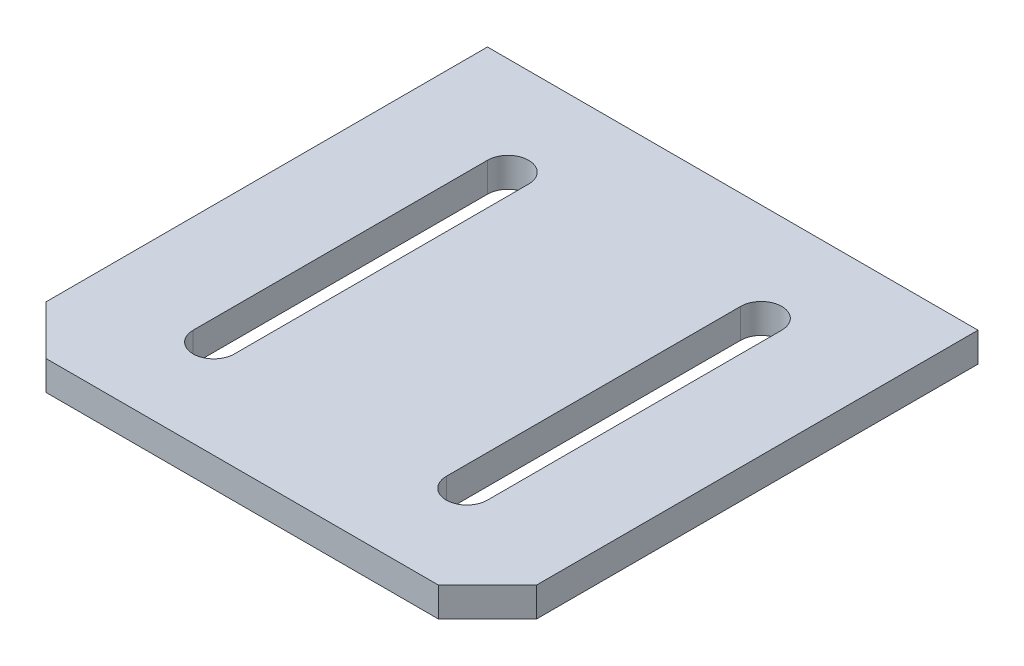
from build123d import *

# Parameters (mm, degrees)
SKETCH1_W           = 50
SKETCH1_H           = 50
BOSS_EXTRUDE1_DEPTH = 3
CHAMFER1_SIZE       = 5
CUT_EXTRUDE1_DEPTH  = 10


with BuildPart() as part:
    # Sketch1 → Boss-Extrude1 (new body)
    with BuildSketch(Plane(origin=(0, 0, 0), x_dir=(1, 0, 0), z_dir=(0, 1, 0))):
        Rectangle(SKETCH1_W, SKETCH1_H)
    extrude(amount=BOSS_EXTRUDE1_DEPTH)

    # Chamfer1
    chamfer1_edges = [part.edges().sort_by_distance(p)[0] for p in [
        (25, 1.5, 25),
        (-25, 1.5, 25),
    ]]
    chamfer(chamfer1_edges, length=CHAMFER1_SIZE)

    # Sketch2 → Cut-Extrude1 (cut)
    with BuildSketch(Plane(origin=(0, 3, 0), x_dir=(1, 0, 0), z_dir=(0, 1, 0))):
        with BuildLine():
            Line((-10.8, -15), (-10.8, 15))
            ThreePointArc((-10.8, 15), (-12.9, 12.9), (-15, 15))
            Line((-15, 15), (-15, -15))
            ThreePointArc((-15, -15), (-12.9, -12.9), (-10.8, -15))
        make_face()
        with BuildLine():
            ThreePointArc((-15, 15), (-12.9, 12.9), (-10.8, 15))
            Line((-10.8, 15), (-15, 15))
        make_face()
        with BuildLine():
            Line((-15, 15), (-10.8, 15))
            ThreePointArc((-10.8, 15), (-12.9, 17.1), (-15, 15))
        make_face()
        with BuildLine():
            ThreePointArc((-15, -15), (-12.9, -17.1), (-10.8, -15))
            Line((-10.8, -15), (-15, -15))
        make_face()
        with BuildLine():
            Line((-15, -15), (-10.8, -15))
            ThreePointArc((-10.8, -15), (-12.9, -12.9), (-15, -15))
        make_face()
        with BuildLine():
            ThreePointArc((15, -15), (12.9, -12.9), (10.8, -15))
            Line((10.8, -15), (15, -15))
        make_face()
        with BuildLine():
            Line((15, -15), (10.8, -15))
            ThreePointArc((10.8, -15), (12.9, -17.1), (15, -15))
        make_face()
        with BuildLine():
            ThreePointArc((15, 15), (12.9, 12.9), (10.8, 15))
            Line((10.8, 15), (10.8, -15))
            ThreePointArc((10.8, -15), (12.9, -12.9), (15, -15))
            Line((15, -15), (15, 15))
        make_face()
        with BuildLine():
            ThreePointArc((15, 15), (12.9, 17.1), (10.8, 15))
            Line((10.8, 15), (15, 15))
        make_face()
        with BuildLine():
            Line((15, 15), (10.8, 15))
            ThreePointArc((10.8, 15), (12.9, 12.9), (15, 15))
        make_face()
    extrude(amount=-CUT_EXTRUDE1_DEPTH, mode=Mode.SUBTRACT)


solid = part.part
